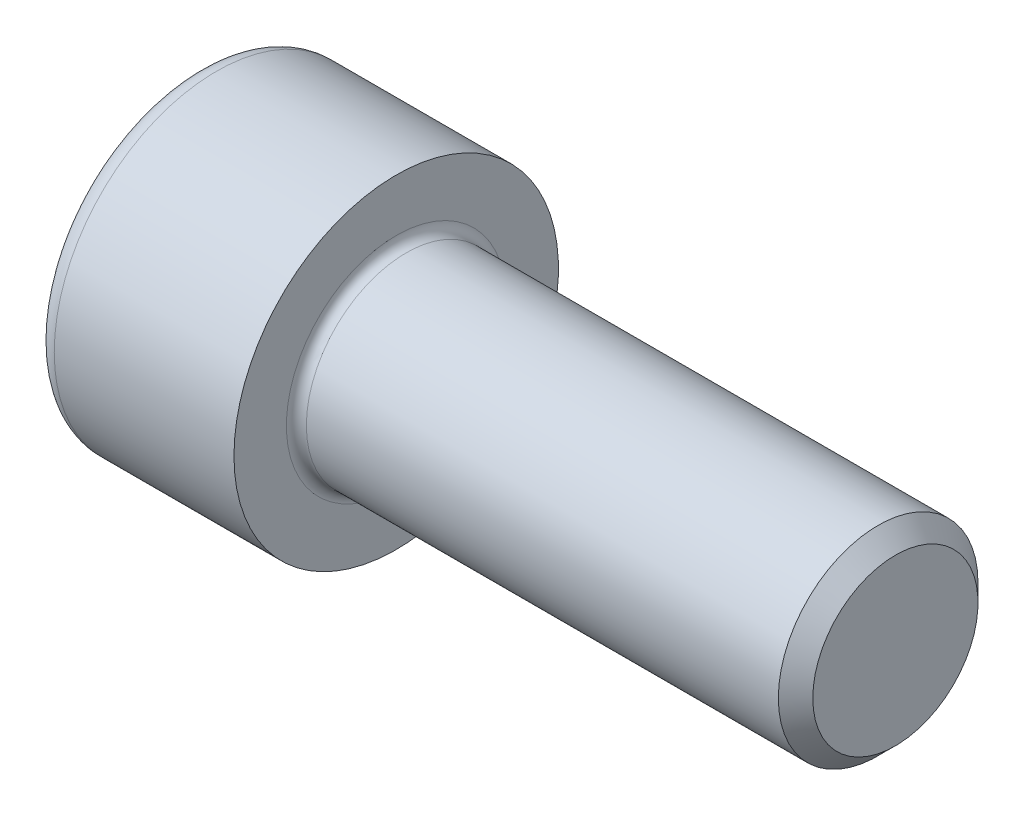
from build123d import *

# Parameters (mm, degrees)
FILLET1_R   = 0.4
FILLET2_R   = 0.8
HEX_2_DEPTH = 4


with BuildPart() as part:
    # BodySke → Base-Revolve (revolve)
    with BuildSketch(Plane.XY):
        Polygon((0, 0), (0, 6.5), (8, 6.5), (8, 4), (27.3095, 4), (28, 3.3095), (28, 0), align=None)
    revolve(axis=Axis((-31.75, 0, 0), (1, 0, 0)))

    # Fillet1
    fillet1_edges = [part.edges().sort_by_distance(p)[0] for p in [
        (8, -4, 0),
    ]]
    fillet(fillet1_edges, radius=FILLET1_R)

    # Fillet2
    fillet2_edges = [part.edges().sort_by_distance(p)[0] for p in [
        (0, -6.5, 0),
    ]]
    fillet(fillet2_edges, radius=FILLET2_R)

    # Sketch2 → Hex-PreBroach (revolve, cut)
    with BuildSketch(Plane.XY):
        Polygon((0, 3.01), (4, 3.01), (5.73782431, 0), (0, 0), align=None)
    revolve(axis=Axis((0, 0, 0), (1, 0, 0)), mode=Mode.SUBTRACT)

    # Sketch3 → Hex 2 (cut)
    with BuildSketch(Plane(origin=(0, 0, 0), x_dir=(0, 0.5, 0.866025404), z_dir=(-1, 0, 0))):
        Polygon((1.73782431, 3.01), (-1.73782431, 3.01), (-3.475648621, 0), (-1.73782431, -3.01), (1.73782431, -3.01), (3.475648621, 0), align=None)
    extrude(amount=-HEX_2_DEPTH, mode=Mode.SUBTRACT)


solid = part.part
